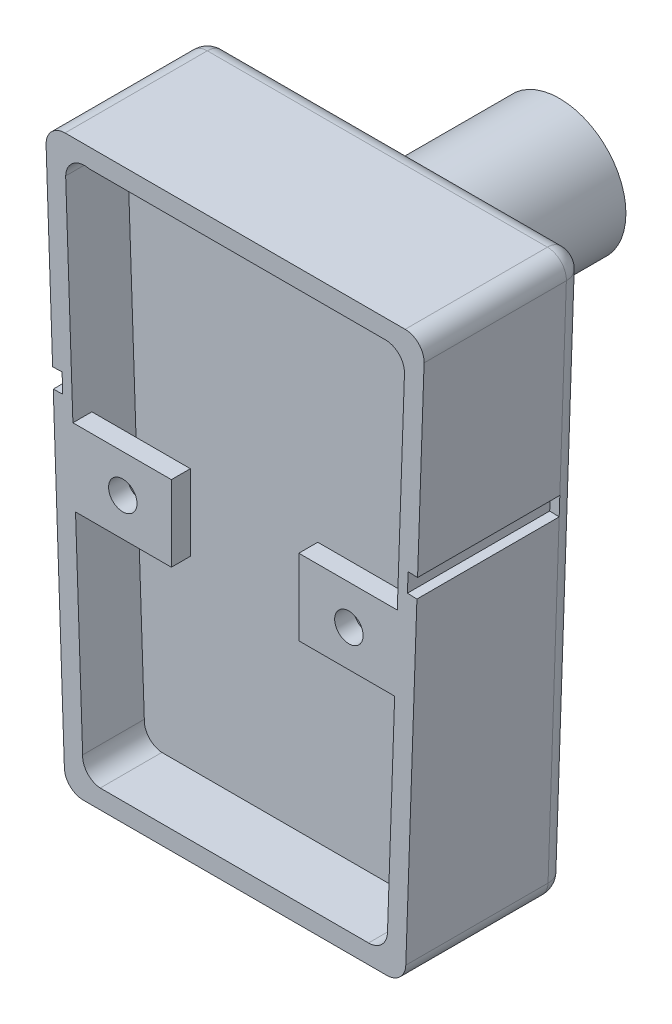
from build123d import *

# Parameters (mm, degrees)
BOSS_EXTRUDE2_DEPTH = 21.59
CUT_EXTRUDE1_DEPTH  = 17.78
BOSS_EXTRUDE4_DEPTH = 2.54
SKETCH8_R           = 1.905
CUT_EXTRUDE2_DEPTH  = 2.54
BOSS_EXTRUDE6_DEPTH = 2.54
FILLET1_R           = 2.54
SKETCH13_W          = 19.05
SKETCH13_H          = 2.54
CUT_EXTRUDE5_DEPTH  = 1.27
CUT_EXTRUDE6_DEPTH  = 1.27
SKETCH16_W          = 19.05
SKETCH16_H          = 2.54
CUT_EXTRUDE7_DEPTH  = 1.27
SKETCH17_R          = 8.89
BOSS_EXTRUDE7_DEPTH = 21.844
FILLET2_R           = 2.54


with BuildPart() as part:
    # Sketch3 → Boss-Extrude2 (new body)
    with BuildSketch(Plane.XY):
        with BuildLine():
            Line((-22.77090231, 76.154735329), (22.77090231, 76.154735329))
            ThreePointArc((22.77090231, 76.154735329), (24.597640016, 75.379566583), (25.309393487, 73.527199387))
            Line((25.309393487, 73.527199387), (22.858491178, 2.452464058))
            ThreePointArc((22.858491178, 2.452464058), (22.084831254, 0.713262294), (20.32, 0))
            Line((20.32, 0), (-20.32, 0))
            ThreePointArc((-20.32, 0), (-22.084831254, 0.713262294), (-22.858491178, 2.452464058))
            Line((-22.858491178, 2.452464058), (-25.309393487, 73.527199387))
            ThreePointArc((-25.309393487, 73.527199387), (-24.597640016, 75.379566583), (-22.77090231, 76.154735329))
        make_face()
    extrude(amount=BOSS_EXTRUDE2_DEPTH)

    # Sketch4 → Cut-Extrude1 (cut)
    with BuildSketch(Plane.XY.offset(21.59)):
        with BuildLine():
            Line((-19.541270744, 73.614735329), (20.141804619, 73.614735329))
            ThreePointArc((20.141804619, 73.614735329), (21.968542325, 72.839566583), (22.680295797, 70.987199387))
            Line((22.680295797, 70.987199387), (20.404569365, 4.992462187))
            ThreePointArc((20.404569365, 4.992462187), (19.630909441, 3.253260423), (17.866078187, 2.539998129))
            Line((17.866078187, 2.539998129), (-18.061159176, 2.539998129))
            ThreePointArc((-18.061159176, 2.539998129), (-19.78310781, 3.39559701), (-20.412160003, 5.212586245))
            Line((-20.412160003, 5.212586245), (-22.687990425, 71.210339105))
            ThreePointArc((-22.687990425, 71.210339105), (-21.690891162, 73.166710129), (-19.541270744, 73.614735329))
        make_face()
    extrude(amount=-CUT_EXTRUDE1_DEPTH, mode=Mode.SUBTRACT)

    # Sketch7 → Boss-Extrude4 (add)
    with BuildSketch(Plane.XY.offset(21.59)):
        Polygon((-21.717608556, 43.069831723), (-8.531459132, 43.069831723), (-8.531459132, 32.909831723), (-21.367256671, 32.909831723), align=None)
        Polygon((8.531459132, 32.909831723), (21.367256671, 32.909831723), (21.717608556, 43.069831723), (8.531459132, 43.069831723), align=None)
    extrude(amount=-BOSS_EXTRUDE4_DEPTH)

    # Sketch8 → Cut-Extrude2 (cut)
    with BuildSketch(Plane.XY.offset(21.59)):
        with Locations((-15.036945873, 37.989831723)):
            Circle(SKETCH8_R)
        with Locations((15.237744036, 37.820383377)):
            Circle(SKETCH8_R)
    extrude(amount=-CUT_EXTRUDE2_DEPTH, mode=Mode.SUBTRACT)

    # Sketch10 → Boss-Extrude6 (add)
    with BuildSketch(Plane.XY.offset(10.795)):
        with BuildLine():
            Line((-19.48633529, 73.614735329), (20.196740073, 73.614735329))
            ThreePointArc((20.196740073, 73.614735329), (22.023477783, 72.839566579), (22.73523125, 70.987199377))
            Line((22.73523125, 70.987199377), (20.459504542, 4.992462177))
            ThreePointArc((20.459504542, 4.992462177), (19.685844615, 3.253260419), (17.921013365, 2.539998129))
            Line((17.921013365, 2.539998129), (-18.006223999, 2.539998129))
            ThreePointArc((-18.006223999, 2.539998129), (-19.816312644, 3.37520138), (-20.468700556, 5.258914571))
            Line((-20.468700556, 5.258914571), (-22.744530979, 71.256667431))
            ThreePointArc((-22.744530979, 71.256667431), (-21.694916693, 73.236386905), (-19.48633529, 73.614735329))
        make_face()
    extrude(amount=BOSS_EXTRUDE6_DEPTH)

    # Fillet1
    fillet1_edges = [part.edges().sort_by_distance(p)[0] for p in [
        (24.083942332, 37.989831723, 0),
        (22.084831254, 0.713262294, 0),
        (0, 0, 0),
        (-22.084831254, 0.713262294, 0),
        (-24.083942332, 37.989831723, 0),
        (-24.597640016, 75.379566583, 0),
        (0, 76.154735329, 0),
        (24.597640016, 75.379566583, 0),
    ]]
    fillet(fillet1_edges, radius=FILLET1_R)

    # Sketch13 → Cut-Extrude5 (cut)
    with BuildSketch(Plane(origin=(22.746873247, -0.784390739, 0), x_dir=(0, 0, -1), z_dir=(0.999405975, -0.034462969, 0))):
        with Locations((-12.065, 47.745550873)):
            Rectangle(SKETCH13_W, SKETCH13_H)
    extrude(amount=-CUT_EXTRUDE5_DEPTH, mode=Mode.SUBTRACT)

    # Sketch14 → Cut-Extrude6 (cut)
    with BuildSketch(Plane(origin=(0, 0, 0), x_dir=(-1, 0, 0), z_dir=(0, 0, -1))):
        Polygon((-21.897084419, 48.274526929), (21.853290434, 48.274526929), (21.853290434, 45.734526929), (-21.809496448, 45.734526929), align=None)
    extrude(amount=-CUT_EXTRUDE6_DEPTH, mode=Mode.SUBTRACT)

    # Sketch16 → Cut-Extrude7 (cut)
    with BuildSketch(Plane(origin=(-22.746873247, -0.784390739, 0), x_dir=(0, 0, 1), z_dir=(-0.999405975, -0.034462969, 0))):
        with Locations((12.065, 47.745550873)):
            Rectangle(SKETCH16_W, SKETCH16_H)
    extrude(amount=-CUT_EXTRUDE7_DEPTH, mode=Mode.SUBTRACT)

    # Sketch17 → Boss-Extrude7 (add)
    with BuildSketch(Plane(origin=(0, 0, 0), x_dir=(-1, 0, 0), z_dir=(0, 0, -1))):
        with Locations((-0.010948496, 60.944631129)):
            Circle(SKETCH17_R)
    extrude(amount=BOSS_EXTRUDE7_DEPTH)

    # Fillet2
    fillet2_edges = [part.edges().sort_by_distance(p)[0] for p in [
        (8.900948496, 60.944631129, 0),
    ]]
    fillet(fillet2_edges, radius=FILLET2_R)


solid = part.part
